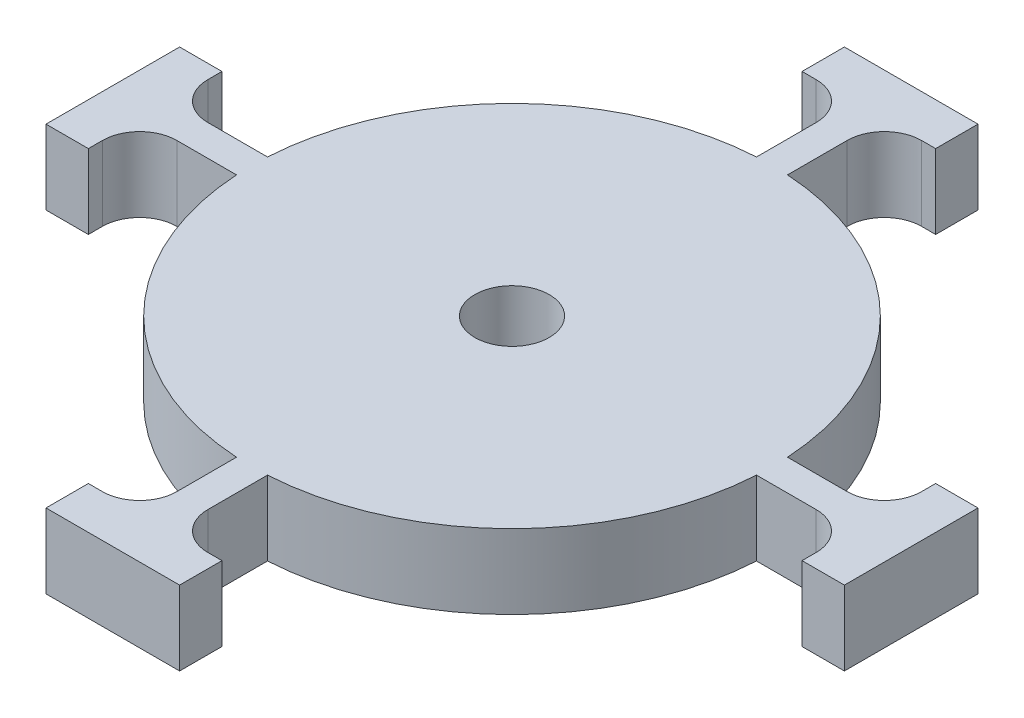
from build123d import *

# Parameters (mm, degrees)
SKETCH1_R           = 5
BOSS_EXTRUDE1_DEPTH = 10
FILLET1_R           = 5


with BuildPart() as part:
    # Sketch1 → Boss-Extrude1 (new body)
    with BuildSketch(Plane(origin=(0, 0, 0), x_dir=(1, 0, 0), z_dir=(0, 1, 0))):
        with BuildLine():
            Line((-2.083872426, 47.950209336), (-2.083872426, 34.937908863))
            ThreePointArc((-2.083872426, 34.937908863), (-24.748737342, 24.748737342), (-34.937908863, 2.083872426))
            Line((-34.937908863, 2.083872426), (-47.950209336, 2.083872426))
            Line((-47.950209336, 2.083872426), (-47.950209336, 8.976599642))
            Line((-47.950209336, 8.976599642), (-53.642672207, 8.976599642))
            Line((-53.642672207, 8.976599642), (-53.642672207, -8.976599642))
            Line((-53.642672207, -8.976599642), (-47.950209336, -8.976599642))
            Line((-47.950209336, -8.976599642), (-47.950209336, -2.083872426))
            Line((-47.950209336, -2.083872426), (-34.937908863, -2.083872426))
            ThreePointArc((-34.937908863, -2.083872426), (-24.748737342, -24.748737342), (-2.083872426, -34.937908863))
            Line((-2.083872426, -34.937908863), (-2.083872426, -47.950209336))
            Line((-2.083872426, -47.950209336), (-8.976599642, -47.950209336))
            Line((-8.976599642, -47.950209336), (-8.976599642, -53.642672207))
            Line((-8.976599642, -53.642672207), (8.976599642, -53.642672207))
            Line((8.976599642, -53.642672207), (8.976599642, -47.950209336))
            Line((8.976599642, -47.950209336), (2.083872426, -47.950209336))
            Line((2.083872426, -47.950209336), (2.083872426, -34.937908863))
            ThreePointArc((2.083872426, -34.937908863), (24.748737342, -24.748737342), (34.937908863, -2.083872426))
            Line((34.937908863, -2.083872426), (47.950209336, -2.083872426))
            Line((47.950209336, -2.083872426), (47.950209336, -8.976599642))
            Line((47.950209336, -8.976599642), (53.642672207, -8.976599642))
            Line((53.642672207, -8.976599642), (53.642672207, 8.976599642))
            Line((53.642672207, 8.976599642), (47.950209336, 8.976599642))
            Line((47.950209336, 8.976599642), (47.950209336, 2.083872426))
            Line((47.950209336, 2.083872426), (34.937908863, 2.083872426))
            ThreePointArc((34.937908863, 2.083872426), (24.748737342, 24.748737342), (2.083872426, 34.937908863))
            Line((2.083872426, 34.937908863), (2.083872426, 47.950209336))
            Line((2.083872426, 47.950209336), (8.976599642, 47.950209336))
            Line((8.976599642, 47.950209336), (8.976599642, 53.642672207))
            Line((8.976599642, 53.642672207), (-8.976599642, 53.642672207))
            Line((-8.976599642, 53.642672207), (-8.976599642, 47.950209336))
            Line((-8.976599642, 47.950209336), (-2.083872426, 47.950209336))
        make_face()
        Circle(SKETCH1_R, mode=Mode.SUBTRACT)
    extrude(amount=BOSS_EXTRUDE1_DEPTH)

    # Fillet1
    fillet1_edges = [part.edges().sort_by_distance(p)[0] for p in [
        (2.083872426, 5, 47.950209336),
        (-2.083872426, 5, 47.950209336),
        (-47.950209336, 5, 2.083872426),
        (-47.950209336, 5, -2.083872426),
        (-2.083872426, 5, -47.950209336),
        (2.083872426, 5, -47.950209336),
        (47.950209336, 5, -2.083872426),
        (47.950209336, 5, 2.083872426),
    ]]
    fillet(fillet1_edges, radius=FILLET1_R)


solid = part.part
